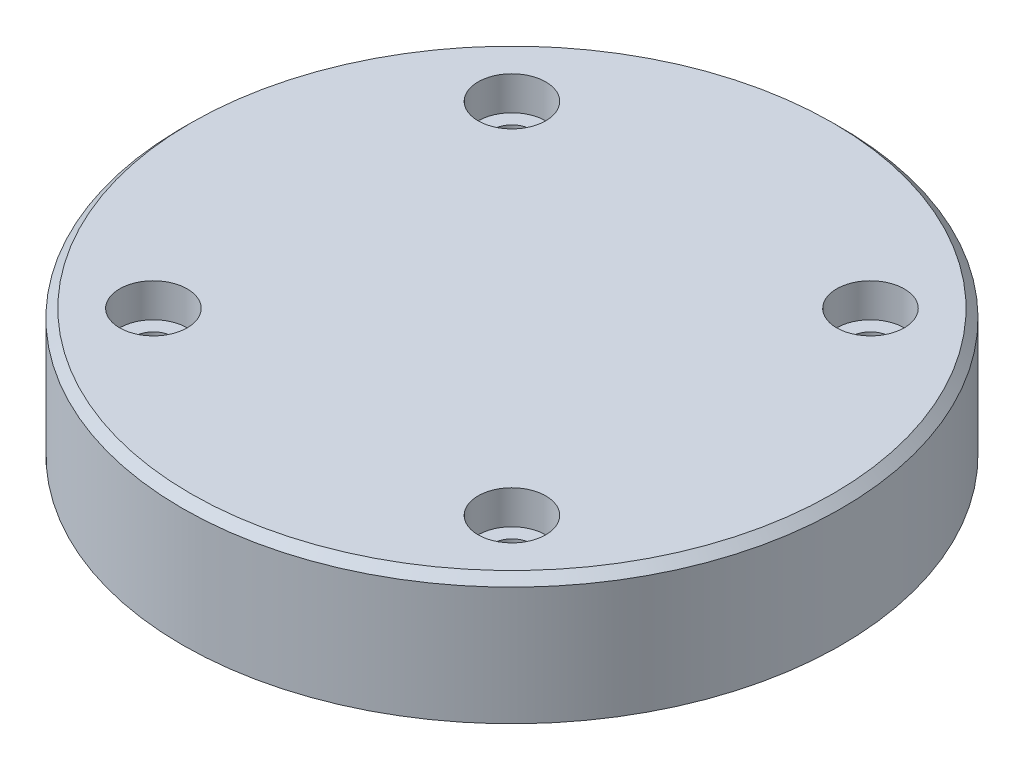
from build123d import *

# Parameters (mm, degrees)
SKETCH1_R                                       = 39
BOSS_EXTRUDE1_DEPTH                             = 15
CBORE_FOR_M4_SOCKET_HEAD_CAP_SCREW1_D           = 4.5
CBORE_FOR_M4_SOCKET_HEAD_CAP_SCREW1_CBORE_D     = 8
CBORE_FOR_M4_SOCKET_HEAD_CAP_SCREW1_CBORE_DEPTH = 4
CHAMFER1_SIZE                                   = 1


with BuildPart() as part:
    # Sketch1 → Boss-Extrude1 (new body)
    with BuildSketch(Plane(origin=(0, 0, 0), x_dir=(1, 0, 0), z_dir=(0, 1, 0))):
        Circle(SKETCH1_R)
    extrude(amount=BOSS_EXTRUDE1_DEPTH)

    # CBORE for M4 Socket Head Cap Screw1 (through all)
    with Locations(Plane(origin=(0, 15, 0), x_dir=(-1, 0, 0), z_dir=(0, 1, 0))):
        with Locations((21.213203436, -21.213203436), (21.213203436, 21.213203436), (-21.213203436, 21.213203436), (-21.213203436, -21.213203436)):
            CounterBoreHole(CBORE_FOR_M4_SOCKET_HEAD_CAP_SCREW1_D / 2, CBORE_FOR_M4_SOCKET_HEAD_CAP_SCREW1_CBORE_D / 2, CBORE_FOR_M4_SOCKET_HEAD_CAP_SCREW1_CBORE_DEPTH)

    # Chamfer1
    chamfer1_edges = [part.edges().sort_by_distance(p)[0] for p in [
        (-39, 15, 0),
    ]]
    chamfer(chamfer1_edges, length=CHAMFER1_SIZE)


solid = part.part
